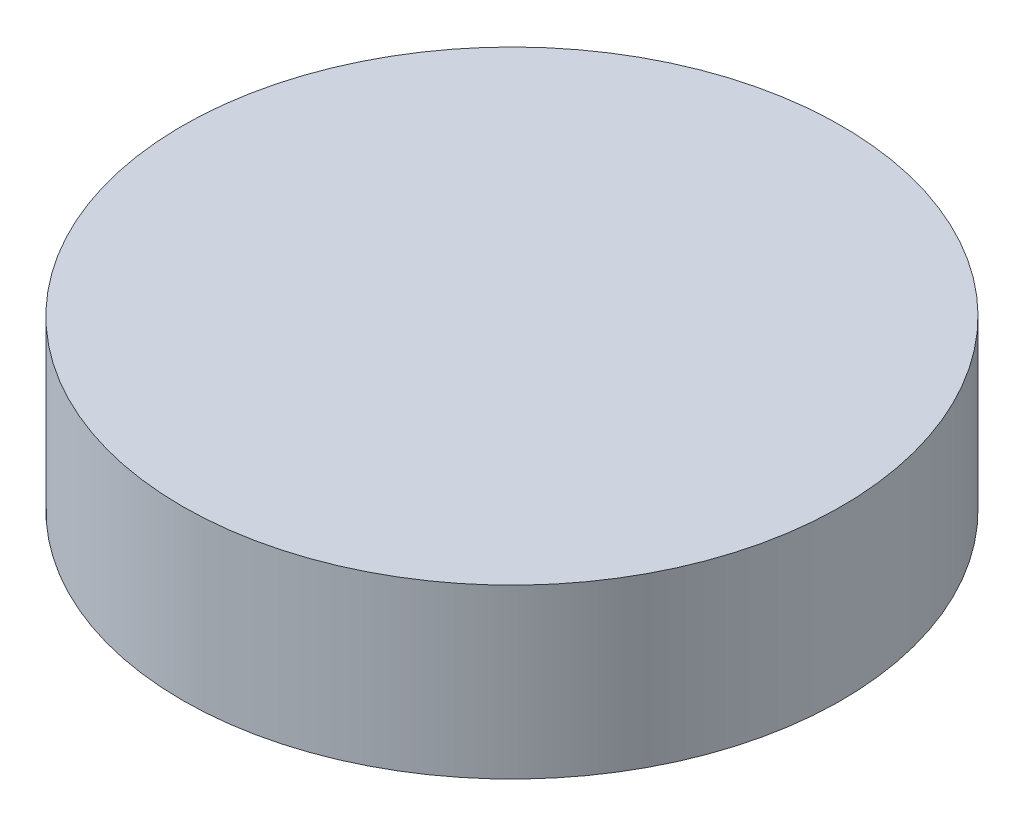
from build123d import *

# Parameters (mm, degrees)
SKETCH1_R           = 1.9939
BOSS_EXTRUDE1_DEPTH = 1.016


with BuildPart() as part:
    # Sketch1 → Boss-Extrude1 (new body)
    with BuildSketch(Plane(origin=(0, 0, 0), x_dir=(1, 0, 0), z_dir=(0, 1, 0))):
        Circle(SKETCH1_R)
    extrude(amount=BOSS_EXTRUDE1_DEPTH)


solid = part.part
